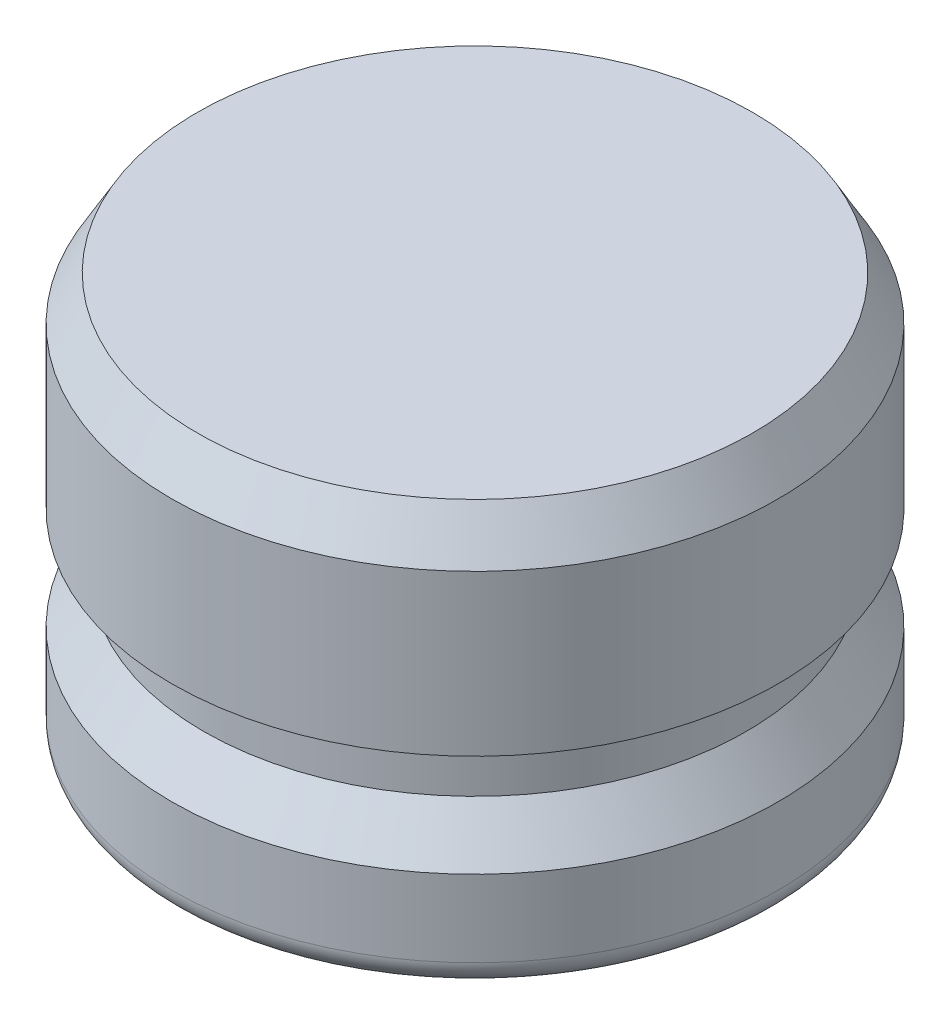
from build123d import *

# Parameters (mm, degrees)
FILLET1_R      = 0.79375
CHAMFER1_SIZE  = 0.79375
CHAMFER1_SIZE2 = 1.374815329


with BuildPart() as part:
    # Sketch1 → Revolve1 (revolve)
    with BuildSketch(Plane.XY):
        Polygon((0, 0), (-9.4234, 0), (-9.4234, 3.175), (-8.4328, 4.572), (-8.4328, 6.35), (-9.4234, 6.35), (-9.4234, 12.7), (0, 12.7), align=None)
    revolve(axis=Axis((0, 0, 0), (0, 1, 0)))

    # Fillet1
    fillet1_edges = [part.edges().sort_by_distance(p)[0] for p in [
        (9.4234, 0, 0),
    ]]
    fillet(fillet1_edges, radius=FILLET1_R)

    # Chamfer1
    chamfer1_edges = [part.edges().sort_by_distance(p)[0] for p in [
        (9.4234, 12.7, 0),
    ]]
    chamfer1_side = [part.faces().sort_by_distance(p)[0] for p in [
        (0, 12.7, 0),
    ]]
    chamfer(chamfer1_edges, length=CHAMFER1_SIZE, length2=CHAMFER1_SIZE2, reference=chamfer1_side[0])


solid = part.part
